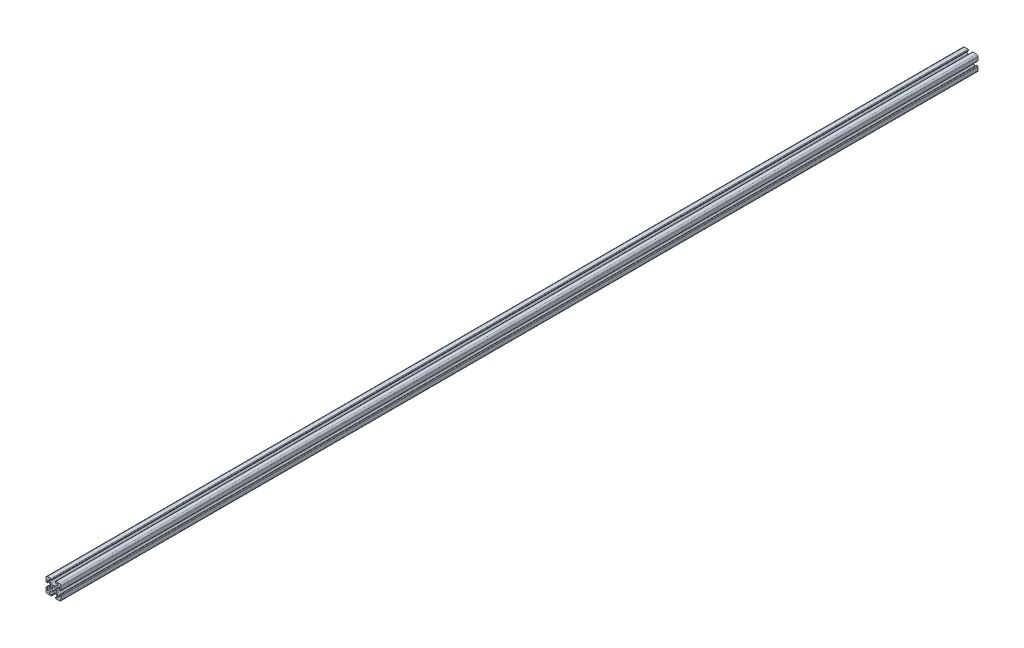
from build123d import *

# Parameters (mm, degrees)
SKETCH3_R                = 2.15
BOSS_EXTRUDE1_DEPTH      = 610
BOSS_EXTRUDE1_DEPTH_BACK = 610


with BuildPart() as part:
    # Sketch3 → Boss-Extrude1 (new body, two sides)
    with BuildSketch(Plane.XY) as boss_extrude1_sk:
        with BuildLine():
            Line((3.2874, 10), (8, 10))
            ThreePointArc((8, 10), (9.414213562, 9.414213562), (10, 8))
            Line((10, 8), (10, 3.2874))
            ThreePointArc((10, 3.2874), (9.76937588, 2.73062412), (9.2126, 2.5))
            Line((9.2126, 2.5), (8.5048, 2.5))
            ThreePointArc((8.5048, 2.5), (8.289273853, 2.589273853), (8.2, 2.8048))
            Line((8.2, 2.8048), (8.2, 4.9118))
            ThreePointArc((8.2, 4.9118), (7.682565253, 5.686195824), (6.769103096, 5.504496904))
            Line((6.769103096, 5.504496904), (4.478679656, 3.214073464))
            ThreePointArc((4.478679656, 3.214073464), (3.828361402, 2.240803418), (3.6, 1.092753121))
            Line((3.6, 1.092753121), (3.6, -1.092753121))
            ThreePointArc((3.6, -1.092753121), (3.828361402, -2.240803418), (4.478679656, -3.214073464))
            Line((4.478679656, -3.214073464), (6.769103096, -5.504496904))
            ThreePointArc((6.769103096, -5.504496904), (7.682565253, -5.686195824), (8.2, -4.9118))
            Line((8.2, -4.9118), (8.2, -2.8048))
            ThreePointArc((8.2, -2.8048), (8.289273853, -2.589273853), (8.5048, -2.5))
            Line((8.5048, -2.5), (9.2126, -2.5))
            ThreePointArc((9.2126, -2.5), (9.76937588, -2.73062412), (10, -3.2874))
            Line((10, -3.2874), (10, -8))
            ThreePointArc((10, -8), (9.414213562, -9.414213562), (8, -10))
            Line((8, -10), (3.2874, -10))
            ThreePointArc((3.2874, -10), (2.73062412, -9.76937588), (2.5, -9.2126))
            Line((2.5, -9.2126), (2.5, -8.5048))
            ThreePointArc((2.5, -8.5048), (2.589273853, -8.289273853), (2.8048, -8.2))
            Line((2.8048, -8.2), (4.9118, -8.2))
            ThreePointArc((4.9118, -8.2), (5.686195824, -7.682565253), (5.504496904, -6.769103096))
            Line((5.504496904, -6.769103096), (3.214073464, -4.478679656))
            ThreePointArc((3.214073464, -4.478679656), (2.240803418, -3.828361402), (1.092753121, -3.6))
            Line((1.092753121, -3.6), (-1.092753121, -3.6))
            ThreePointArc((-1.092753121, -3.6), (-2.240803418, -3.828361402), (-3.214073464, -4.478679656))
            Line((-3.214073464, -4.478679656), (-5.504496904, -6.769103096))
            ThreePointArc((-5.504496904, -6.769103096), (-5.686195824, -7.682565253), (-4.9118, -8.2))
            Line((-4.9118, -8.2), (-2.8048, -8.2))
            ThreePointArc((-2.8048, -8.2), (-2.589273853, -8.289273853), (-2.5, -8.5048))
            Line((-2.5, -8.5048), (-2.5, -9.2126))
            ThreePointArc((-2.5, -9.2126), (-2.73062412, -9.76937588), (-3.2874, -10))
            Line((-3.2874, -10), (-8, -10))
            ThreePointArc((-8, -10), (-9.414213562, -9.414213562), (-10, -8))
            Line((-10, -8), (-10, -3.2874))
            ThreePointArc((-10, -3.2874), (-9.76937588, -2.73062412), (-9.2126, -2.5))
            Line((-9.2126, -2.5), (-8.5048, -2.5))
            ThreePointArc((-8.5048, -2.5), (-8.289273853, -2.589273853), (-8.2, -2.8048))
            Line((-8.2, -2.8048), (-8.2, -4.9118))
            ThreePointArc((-8.2, -4.9118), (-7.682565253, -5.686195824), (-6.769103096, -5.504496904))
            Line((-6.769103096, -5.504496904), (-4.478679656, -3.214073464))
            ThreePointArc((-4.478679656, -3.214073464), (-3.828361402, -2.240803418), (-3.6, -1.092753121))
            Line((-3.6, -1.092753121), (-3.6, 1.092753121))
            ThreePointArc((-3.6, 1.092753121), (-3.828361402, 2.240803418), (-4.478679656, 3.214073464))
            Line((-4.478679656, 3.214073464), (-6.769103096, 5.504496904))
            ThreePointArc((-6.769103096, 5.504496904), (-7.682565253, 5.686195824), (-8.2, 4.9118))
            Line((-8.2, 4.9118), (-8.2, 2.8048))
            ThreePointArc((-8.2, 2.8048), (-8.289273853, 2.589273853), (-8.5048, 2.5))
            Line((-8.5048, 2.5), (-9.2126, 2.5))
            ThreePointArc((-9.2126, 2.5), (-9.76937588, 2.73062412), (-10, 3.2874))
            Line((-10, 3.2874), (-10, 8))
            ThreePointArc((-10, 8), (-9.414213562, 9.414213562), (-8, 10))
            Line((-8, 10), (-3.2874, 10))
            ThreePointArc((-3.2874, 10), (-2.73062412, 9.76937588), (-2.5, 9.2126))
            Line((-2.5, 9.2126), (-2.5, 8.5048))
            ThreePointArc((-2.5, 8.5048), (-2.589273853, 8.289273853), (-2.8048, 8.2))
            Line((-2.8048, 8.2), (-4.9118, 8.2))
            ThreePointArc((-4.9118, 8.2), (-5.686195824, 7.682565253), (-5.504496904, 6.769103096))
            Line((-5.504496904, 6.769103096), (-3.214073464, 4.478679656))
            ThreePointArc((-3.214073464, 4.478679656), (-2.240803418, 3.828361402), (-1.092753121, 3.6))
            Line((-1.092753121, 3.6), (1.092753121, 3.6))
            ThreePointArc((1.092753121, 3.6), (2.240803418, 3.828361402), (3.214073464, 4.478679656))
            Line((3.214073464, 4.478679656), (5.504496904, 6.769103096))
            ThreePointArc((5.504496904, 6.769103096), (5.686195824, 7.682565253), (4.9118, 8.2))
            Line((4.9118, 8.2), (2.8048, 8.2))
            ThreePointArc((2.8048, 8.2), (2.589273853, 8.289273853), (2.5, 8.5048))
            Line((2.5, 8.5048), (2.5, 9.2126))
            ThreePointArc((2.5, 9.2126), (2.73062412, 9.76937588), (3.2874, 10))
        make_face()
        Circle(SKETCH3_R, mode=Mode.SUBTRACT)
    extrude(amount=BOSS_EXTRUDE1_DEPTH)
    extrude(boss_extrude1_sk.sketch, amount=-BOSS_EXTRUDE1_DEPTH_BACK)


solid = part.part
